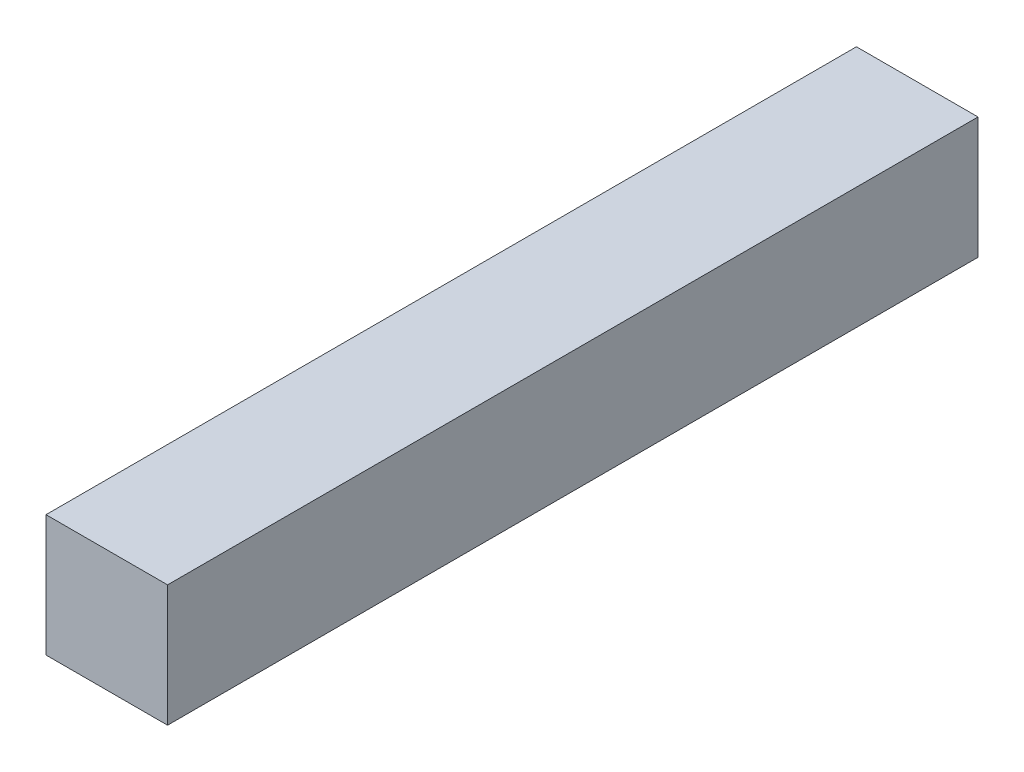
from build123d import *

# Parameters (mm, degrees)
SKETCH1_W           = 38.1
SKETCH1_H           = 38.1
BOSS_EXTRUDE1_DEPTH = 254


with BuildPart() as part:
    # Sketch1 → Boss-Extrude1 (new body)
    with BuildSketch(Plane.XY):
        with Locations((19.05, 19.05)):
            Rectangle(SKETCH1_W, SKETCH1_H)
    extrude(amount=BOSS_EXTRUDE1_DEPTH)


solid = part.part
